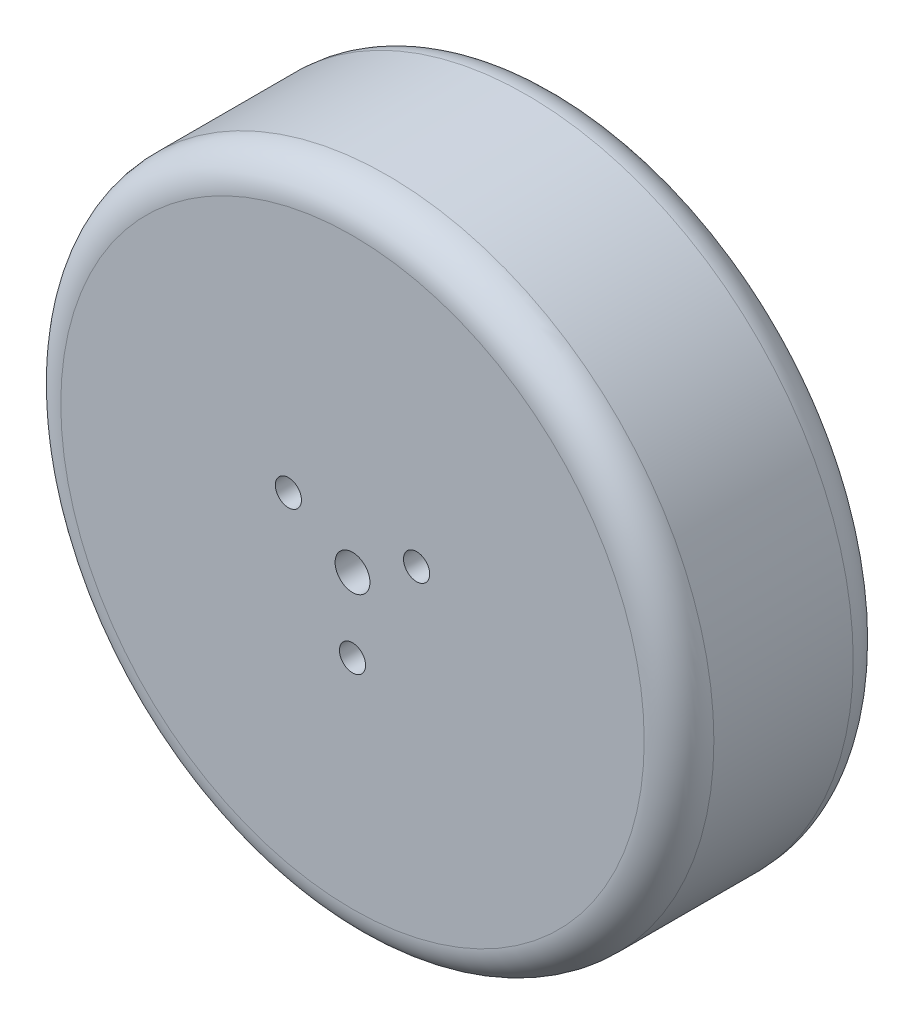
from build123d import *

# Parameters (mm, degrees)
SKETCH1_R           = 37.5
BOSS_EXTRUDE2_DEPTH = 24
FILLET1_R           = 4
SKETCH2_R           = 2
CUT_EXTRUDE1_DEPTH  = 24
SKETCH3_R           = 1.5
CUT_EXTRUDE3_DEPTH  = 25
CIRPATTERN1_COUNT   = 3


with BuildPart() as part:
    # Sketch1 → Boss-Extrude2 (new body)
    with BuildSketch(Plane.XY):
        Circle(SKETCH1_R)
    extrude(amount=BOSS_EXTRUDE2_DEPTH)

    # Fillet1
    fillet1_edges = [part.edges().sort_by_distance(p)[0] for p in [
        (-37.5, 0, 0),
        (-37.5, 0, 24),
    ]]
    fillet(fillet1_edges, radius=FILLET1_R)

    # Sketch2 → Cut-Extrude1 (cut)
    with BuildSketch(Plane.XY.offset(24)):
        Circle(SKETCH2_R)
    extrude(amount=-CUT_EXTRUDE1_DEPTH, mode=Mode.SUBTRACT)

    # Sketch3 → Cut-Extrude3 (cut, through all)
    with BuildSketch(Plane.XY.offset(24)):
        with Locations((0, -8.5)):
            Circle(SKETCH3_R)
    cut_extrude3 = extrude(amount=-CUT_EXTRUDE3_DEPTH, mode=Mode.SUBTRACT)

    # CirPattern1: Cut-Extrude3 ×3 about axis
    cirpattern1_axis = Axis((0, 0, 0), (0, 0, 1))
    for i in range(1, CIRPATTERN1_COUNT):
        add(cut_extrude3.rotate(cirpattern1_axis, i * 360 / CIRPATTERN1_COUNT), mode=Mode.SUBTRACT)


solid = part.part
